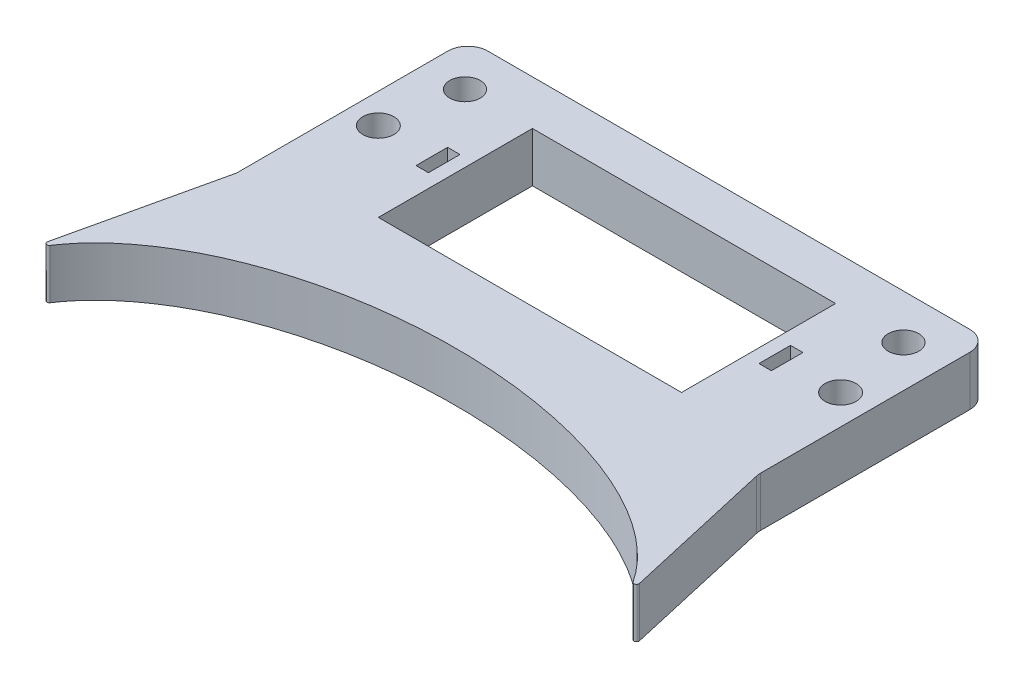
from build123d import *

# Parameters (mm, degrees)
SKETCH1_W           = 105
SKETCH1_H           = 55
BOSS_EXTRUDE1_DEPTH = 10
SKETCH2_W           = 61
SKETCH2_H           = 31
CUT_EXTRUDE1_DEPTH  = 11
SKETCH4_R           = 3.125
SKETCH4_W           = 2.5
SKETCH4_H           = 6.35
CUT_EXTRUDE3_DEPTH  = 11
BOSS_EXTRUDE2_DEPTH = 10
SKETCH6_R           = 3.075
CUT_EXTRUDE4_DEPTH  = 11.0000001
FILLET1_R           = 4
FILLET2_R           = 0.5


with BuildPart() as part:
    # Sketch1 → Boss-Extrude1 (new body)
    with BuildSketch(Plane(origin=(0, 0, 0), x_dir=(1, 0, 0), z_dir=(0, 1, 0))):
        Rectangle(SKETCH1_W, SKETCH1_H)
    extrude(amount=BOSS_EXTRUDE1_DEPTH)

    # Sketch2 → Cut-Extrude1 (cut, through all)
    with BuildSketch(Plane(origin=(0, 10, 0), x_dir=(1, 0, 0), z_dir=(0, 1, 0))):
        with Locations((0, 3)):
            Rectangle(SKETCH2_W, SKETCH2_H)
    extrude(amount=-CUT_EXTRUDE1_DEPTH, mode=Mode.SUBTRACT)

    # Sketch4 → Cut-Extrude3 (cut, through all)
    with BuildSketch(Plane(origin=(0, 10, 0), x_dir=(1, 0, 0), z_dir=(0, 1, 0))):
        with Locations((-46.5, 3.5)):
            Circle(SKETCH4_R)
        with Locations((-34.5, 3.5)):
            Rectangle(SKETCH4_W, SKETCH4_H)
    cut_extrude3 = extrude(amount=-CUT_EXTRUDE3_DEPTH, mode=Mode.SUBTRACT)

    # Sketch5 → Boss-Extrude2 (add)
    with BuildSketch(Plane(origin=(0, 0, 0), x_dir=(1, 0, 0), z_dir=(0, 1, 0))):
        with BuildLine():
            Line((0, -27.5), (-52.5, -19.039128985))
            Line((-52.5, -19.039128985), (-60.28224578, -53.259137237))
            add(Edge.make_bspline(
                [(0, -27.5), (-47.690720084, -27.5), (-60.28224578, -53.259137237)],
                knots=[4.71238898, 4.71238898, 4.71238898, 6.015992757, 6.015992757, 6.015992757], degree=2, weights=[1, 0.794992028, 1]))
        make_face()
    boss_extrude2 = extrude(amount=BOSS_EXTRUDE2_DEPTH)

    # Sketch6 → Cut-Extrude4 (cut, through all)
    with BuildSketch(Plane(origin=(0, 10, 0), x_dir=(1, 0, 0), z_dir=(0, 1, 0))):
        with Locations((-44.108495475, 18.541732167)):
            Circle(SKETCH6_R)
    cut_extrude4 = extrude(amount=-CUT_EXTRUDE4_DEPTH, mode=Mode.SUBTRACT)

    # Mirror1: Cut-Extrude3, Boss-Extrude2, Cut-Extrude4 across plane
    add(cut_extrude3.mirror(Plane(origin=(0, 0, 0), x_dir=(0, 0, 1), z_dir=(1, 0, 0))), mode=Mode.SUBTRACT)
    add(boss_extrude2.mirror(Plane(origin=(0, 0, 0), x_dir=(0, 0, 1), z_dir=(1, 0, 0))))
    add(cut_extrude4.mirror(Plane(origin=(0, 0, 0), x_dir=(0, 0, 1), z_dir=(1, 0, 0))), mode=Mode.SUBTRACT)

    # Fillet1
    fillet1_edges = [part.edges().sort_by_distance(p)[0] for p in [
        (-52.5, 5, 19.039128985),
        (-52.5, 5, -27.5),
        (52.5, 5, -27.5),
        (52.5, 5, 19.039128985),
    ]]
    fillet(fillet1_edges, radius=FILLET1_R)

    # Fillet2
    fillet2_edges = [part.edges().sort_by_distance(p)[0] for p in [
        (60.28224578, 5, 53.259137237),
        (-60.28224578, 5, 53.259137237),
    ]]
    fillet(fillet2_edges, radius=FILLET2_R)


solid = part.part
